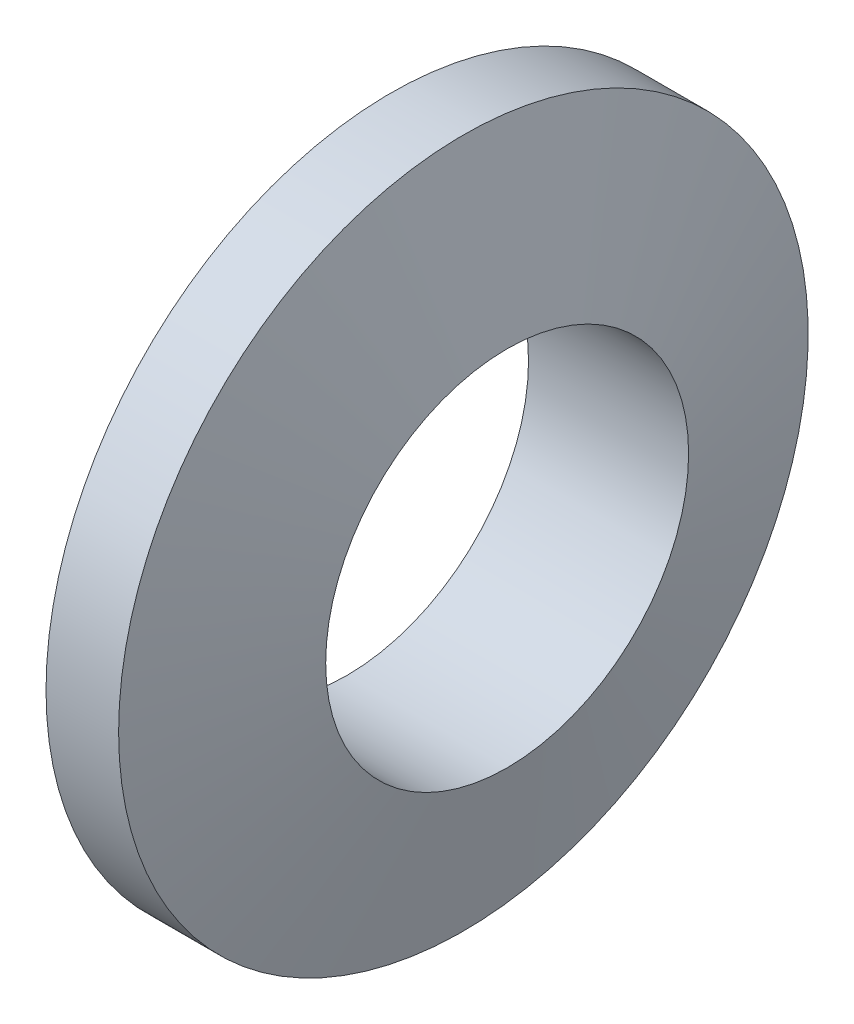
from build123d import *


with BuildPart() as part:
    # Ske → Revolve 399 (revolve)
    with BuildSketch(Plane.XY):
        Polygon((-1, 9.5), (1, 9.5), (2.205771366, 5), (-2.205771366, 5), align=None)
    revolve(axis=Axis((-10, 0, 0), (1, 0, 0)))


solid = part.part
